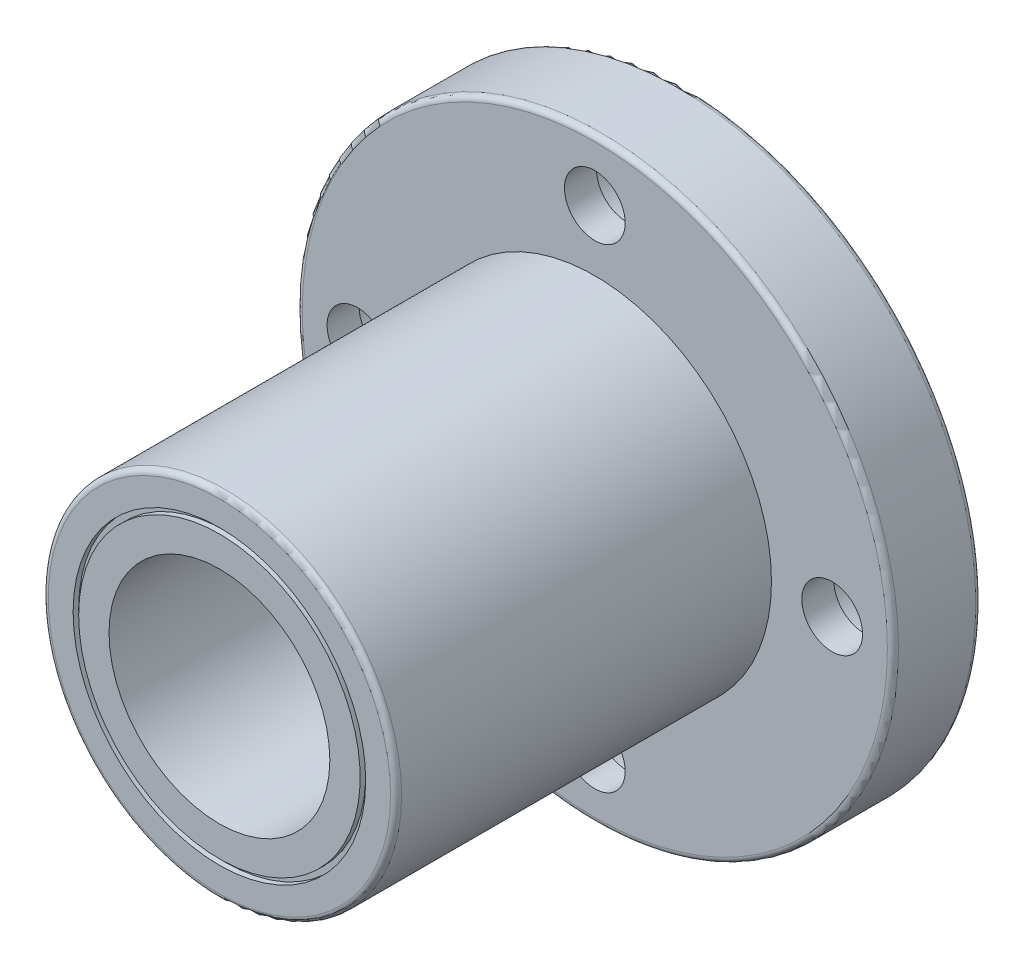
from build123d import *

# Parameters (mm, degrees)
PADR_OCIRCULAR1_COUNT = 4
FILETE1_R             = 0.5


with BuildPart() as part:
    # Esboço1 → Revolução1 (revolve)
    with BuildSketch(Plane(origin=(0, 0, 0), x_dir=(0, 0, -1), z_dir=(1, 0, 0)), mode=Mode.PRIVATE) as revolu_o1_sk:
        Polygon((0, 10), (0, 12.75), (-0.5, 12.75), (-0.5, 13.25), (0, 13.25), (0, 15.5), (-0.5, 15.5), (-0.5, 16), (0, 16), (0, 27), (-8, 27), (-8, 16), (-42, 16), (-42, 13.25), (-41.5, 13.25), (-41.5, 12.75), (-42, 12.75), (-42, 10), align=None)
    revolve(revolu_o1_sk.sketch.rotate(Axis((0, 0, 0), (0, 0, 1)), 90), axis=Axis((0, 0, 0), (0, 0, 1)))  # turned: the seam where the file's is

    # Esboço5 → Corte-Revolução1 (revolve, cut)
    with BuildSketch(Plane(origin=(0, 0, 0), x_dir=(0, 0, -1), z_dir=(1, 0, 0)), mode=Mode.PRIVATE) as corte_revolu_o1_sk:
        Polygon((0, 26), (-5.1, 26), (-5.1, 24.25), (-8, 24.25), (-8, 21.5), (0, 21.5), align=None)
    corte_revolu_o1 = revolve(corte_revolu_o1_sk.sketch.rotate(Axis((0, 21.5, 0), (0, 0, -1)), 90), axis=Axis((0, 21.5, 0), (0, 0, -1)), mode=Mode.SUBTRACT)  # turned: the seam where the file's is

    # PadrãoCircular1: Corte-Revolução1 ×4 about axis
    padr_ocircular1_axis = Axis((0, 0, 0), (0, 0, 1))
    for i in range(1, PADR_OCIRCULAR1_COUNT):
        add(corte_revolu_o1.rotate(padr_ocircular1_axis, i * 360 / PADR_OCIRCULAR1_COUNT), mode=Mode.SUBTRACT)

    # Filete1
    filete1_edges = [part.edges().sort_by_distance(p)[0] for p in [
        (16, 0, 42),
        (27, 0, 8),
        (27, 0, 0),
    ]]
    fillet(filete1_edges, radius=FILETE1_R)


solid = part.part
